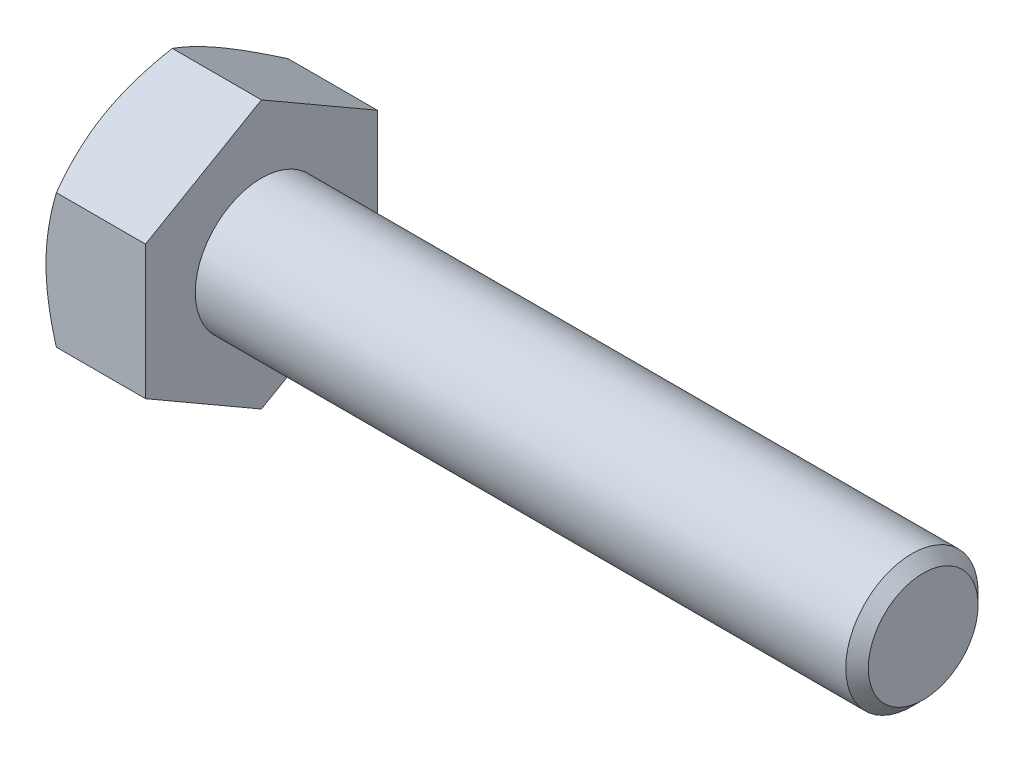
from build123d import *

# Parameters (mm, degrees)
BASEHEAD_DEPTH = 4.7752


with BuildPart() as part:
    # Sketch1 → BaseHead (new body)
    with BuildSketch(Plane(origin=(0, 0, 0), x_dir=(0, 0, -1), z_dir=(1, 0, 0))):
        Polygon((5.5626, 3.211568607), (5.5626, -3.211568607), (0, -6.423137215), (-5.5626, -3.211568607), (-5.5626, 3.211568607), (0, 6.423137215), align=None)
    extrude(amount=BASEHEAD_DEPTH)

    # BodySke → BaseBody (revolve)
    with BuildSketch(Plane.XY):
        Polygon((0, 0), (36.5252, 0), (36.5252, 2.63398), (35.98418, 3.175), (0, 3.175), align=None)
    revolve(axis=Axis((0, 0, 0), (1, 0, 0)))

    # Sketch3 → HeadChamfer (revolve, cut)
    with BuildSketch(Plane.XY):
        Polygon((0, 5.5626), (4.163005602, 12.773137215), (4.163005602, 19.123137215), (-12.7, 19.123137215), (-12.7, 5.5626), align=None)
    revolve(axis=Axis((0, 0, 0), (1, 0, 0)), mode=Mode.SUBTRACT)


solid = part.part
